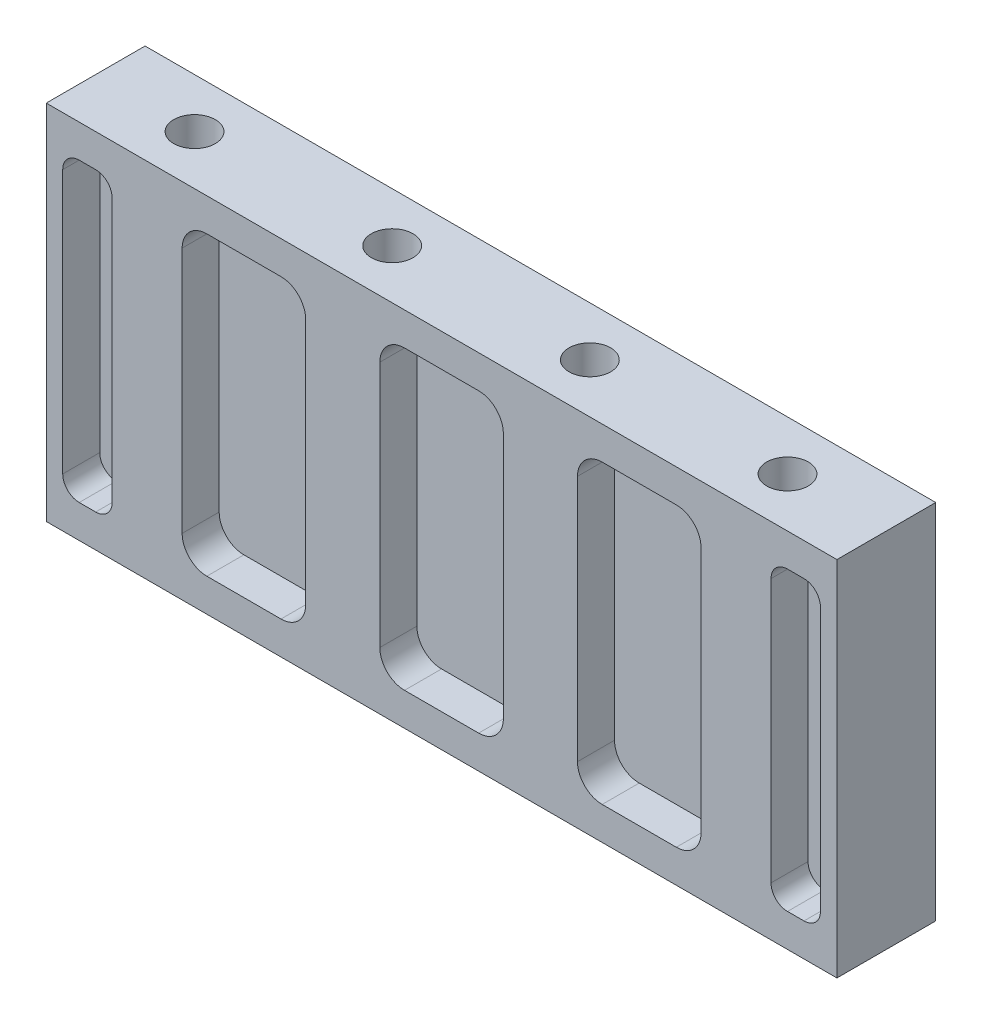
from build123d import *

# Parameters (mm, degrees)
SKETCH1_W           = 152.4
SKETCH1_H           = 69.85
BOSS_EXTRUDE1_DEPTH = 19.05
CUT_EXTRUDE1_DEPTH  = 7.1374
CUT_EXTRUDE2_REACH  = 71.85
SKETCH3_R           = 4.0132


with BuildPart() as part:
    # Sketch1 → Boss-Extrude1 (new body)
    with BuildSketch(Plane.XY):
        Rectangle(SKETCH1_W, SKETCH1_H)
    extrude(amount=BOSS_EXTRUDE1_DEPTH)

    # Sketch2 → Cut-Extrude1 (cut)
    with BuildSketch(Plane.XY.offset(19.05)):
        with BuildLine():
            Line((-45.24375, 28.575), (-30.95625, 28.575))
            ThreePointArc((-30.95625, 28.575), (-27.588653955, 27.180096045), (-26.19375, 23.8125))
            Line((-26.19375, 23.8125), (-26.19375, -23.8125))
            ThreePointArc((-26.19375, -23.8125), (-27.588653955, -27.180096045), (-30.95625, -28.575))
            Line((-30.95625, -28.575), (-45.24375, -28.575))
            ThreePointArc((-45.24375, -28.575), (-48.611346045, -27.180096045), (-50.00625, -23.8125))
            Line((-50.00625, -23.8125), (-50.00625, 23.8125))
            ThreePointArc((-50.00625, 23.8125), (-48.611346045, 27.180096045), (-45.24375, 28.575))
        make_face()
        with BuildLine():
            Line((7.14375, 28.575), (-7.14375, 28.575))
            ThreePointArc((-7.14375, 28.575), (-10.511346045, 27.180096045), (-11.90625, 23.8125))
            Line((-11.90625, 23.8125), (-11.90625, -23.8125))
            ThreePointArc((-11.90625, -23.8125), (-10.511346045, -27.180096045), (-7.14375, -28.575))
            Line((-7.14375, -28.575), (7.14375, -28.575))
            ThreePointArc((7.14375, -28.575), (10.511346045, -27.180096045), (11.90625, -23.8125))
            Line((11.90625, -23.8125), (11.90625, 23.8125))
            ThreePointArc((11.90625, 23.8125), (10.511346045, 27.180096045), (7.14375, 28.575))
        make_face()
        with BuildLine():
            Line((30.95625, 28.575), (45.24375, 28.575))
            ThreePointArc((45.24375, 28.575), (48.611346045, 27.180096045), (50.00625, 23.8125))
            Line((50.00625, 23.8125), (50.00625, -23.8125))
            ThreePointArc((50.00625, -23.8125), (48.611346045, -27.180096045), (45.24375, -28.575))
            Line((45.24375, -28.575), (30.95625, -28.575))
            ThreePointArc((30.95625, -28.575), (27.588653955, -27.180096045), (26.19375, -23.8125))
            Line((26.19375, -23.8125), (26.19375, 23.8125))
            ThreePointArc((26.19375, 23.8125), (27.588653955, 27.180096045), (30.95625, 28.575))
        make_face()
        with BuildLine():
            Line((-69.85, 28.575), (-66.675, 28.575))
            ThreePointArc((-66.675, 28.575), (-64.42993597, 27.64506403), (-63.5, 25.4))
            Line((-63.5, 25.4), (-63.5, -25.4))
            ThreePointArc((-63.5, -25.4), (-64.42993597, -27.64506403), (-66.675, -28.575))
            Line((-66.675, -28.575), (-69.85, -28.575))
            ThreePointArc((-69.85, -28.575), (-72.09506403, -27.64506403), (-73.025, -25.4))
            Line((-73.025, -25.4), (-73.025, 25.4))
            ThreePointArc((-73.025, 25.4), (-72.09506403, 27.64506403), (-69.85, 28.575))
        make_face()
        with BuildLine():
            Line((66.675, 28.575), (69.85, 28.575))
            ThreePointArc((69.85, 28.575), (72.09506403, 27.64506403), (73.025, 25.4))
            Line((73.025, 25.4), (73.025, -25.4))
            ThreePointArc((73.025, -25.4), (72.09506403, -27.64506403), (69.85, -28.575))
            Line((69.85, -28.575), (66.675, -28.575))
            ThreePointArc((66.675, -28.575), (64.42993597, -27.64506403), (63.5, -25.4))
            Line((63.5, -25.4), (63.5, 25.4))
            ThreePointArc((63.5, 25.4), (64.42993597, 27.64506403), (66.675, 28.575))
        make_face()
    extrude(amount=-CUT_EXTRUDE1_DEPTH, mode=Mode.SUBTRACT)

    # Sketch3 → Cut-Extrude2 (cut, up to next)
    with BuildSketch(Plane(origin=(0, 34.925, 0), x_dir=(1, 0, 0), z_dir=(0, 1, 0)), mode=Mode.PRIVATE) as cut_extrude2_sk1:
        with Locations(Location((-57.15, -9.525, 0), (0, 0, 270))):  # turned: the seam where the file's is
            Circle(SKETCH3_R)
    cut_extrude2_tool1 = extrude(cut_extrude2_sk1.sketch, amount=-CUT_EXTRUDE2_REACH, mode=Mode.PRIVATE) & part.part
    add(cut_extrude2_tool1.solids().sort_by_distance((-57.15, 34.925, 9.525))[0], mode=Mode.SUBTRACT)
    # Sketch3 → Cut-Extrude2 (cut, up to next)
    with BuildSketch(Plane(origin=(0, 34.925, 0), x_dir=(1, 0, 0), z_dir=(0, 1, 0)), mode=Mode.PRIVATE) as cut_extrude2_sk2:
        with Locations(Location((-19.05, -9.525, 0), (0, 0, 270))):  # turned: the seam where the file's is
            Circle(SKETCH3_R)
    cut_extrude2_tool2 = extrude(cut_extrude2_sk2.sketch, amount=-CUT_EXTRUDE2_REACH, mode=Mode.PRIVATE) & part.part
    add(cut_extrude2_tool2.solids().sort_by_distance((-19.05, 34.925, 9.525))[0], mode=Mode.SUBTRACT)
    # Sketch3 → Cut-Extrude2 (cut, up to next)
    with BuildSketch(Plane(origin=(0, 34.925, 0), x_dir=(1, 0, 0), z_dir=(0, 1, 0)), mode=Mode.PRIVATE) as cut_extrude2_sk3:
        with Locations(Location((19.05, -9.525, 0), (0, 0, 270))):  # turned: the seam where the file's is
            Circle(SKETCH3_R)
    cut_extrude2_tool3 = extrude(cut_extrude2_sk3.sketch, amount=-CUT_EXTRUDE2_REACH, mode=Mode.PRIVATE) & part.part
    add(cut_extrude2_tool3.solids().sort_by_distance((19.05, 34.925, 9.525))[0], mode=Mode.SUBTRACT)
    # Sketch3 → Cut-Extrude2 (cut, up to next)
    with BuildSketch(Plane(origin=(0, 34.925, 0), x_dir=(1, 0, 0), z_dir=(0, 1, 0)), mode=Mode.PRIVATE) as cut_extrude2_sk4:
        with Locations(Location((57.15, -9.525, 0), (0, 0, 270))):  # turned: the seam where the file's is
            Circle(SKETCH3_R)
    cut_extrude2_tool4 = extrude(cut_extrude2_sk4.sketch, amount=-CUT_EXTRUDE2_REACH, mode=Mode.PRIVATE) & part.part
    add(cut_extrude2_tool4.solids().sort_by_distance((57.15, 34.925, 9.525))[0], mode=Mode.SUBTRACT)


solid = part.part
